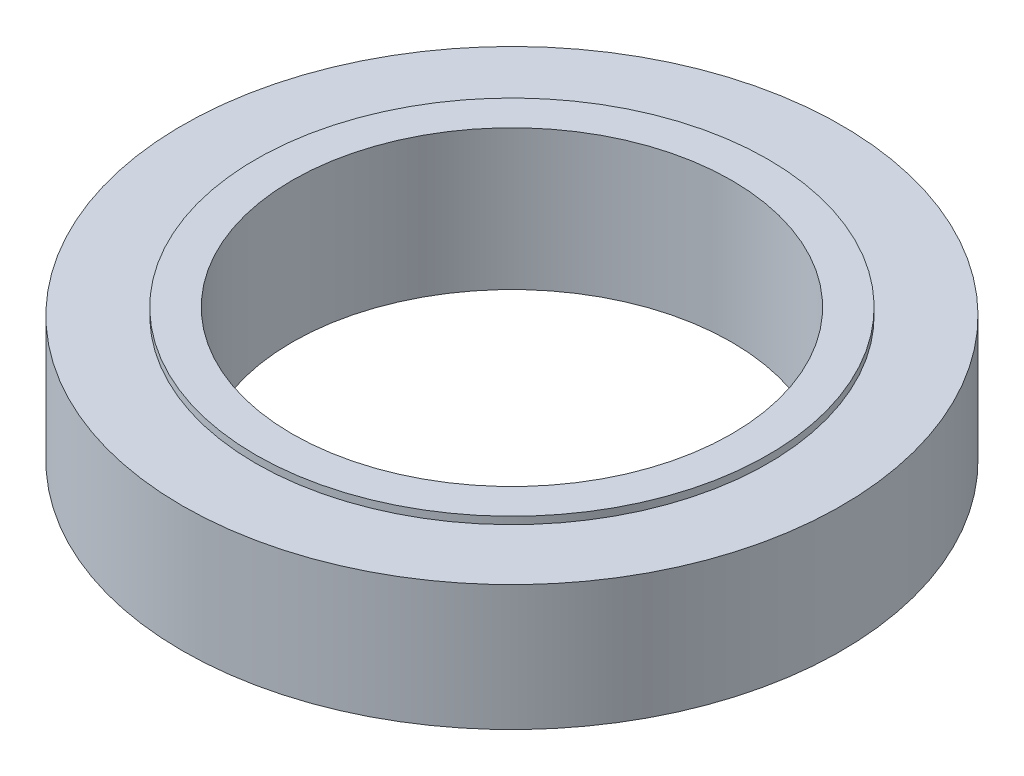
from build123d import *

# Parameters (mm, degrees)
SKETCH2_R           = 16.66875
SKETCH2_R_2         = 11.1125
BOSS_EXTRUDE1_DEPTH = 3.175
SKETCH2_3_R         = 12.954
SKETCH2_3_R_2       = 11.1125
BOSS_EXTRUDE2_DEPTH = 3.5433


with BuildPart() as part:
    # Sketch2 → Boss-Extrude1 (new, symmetric)
    with BuildSketch(Plane(origin=(0, 0, 0), x_dir=(1, 0, 0), z_dir=(0, 1, 0))):
        Circle(SKETCH2_R)
        Circle(SKETCH2_R_2, mode=Mode.SUBTRACT)
    extrude(amount=BOSS_EXTRUDE1_DEPTH, both=True)

    # Sketch2_3 → Boss-Extrude2 (add, symmetric)
    with BuildSketch(Plane(origin=(0, 0, 0), x_dir=(1, 0, 0), z_dir=(0, 1, 0))):
        Circle(SKETCH2_3_R)
        Circle(SKETCH2_3_R_2, mode=Mode.SUBTRACT)
    extrude(amount=BOSS_EXTRUDE2_DEPTH, both=True)


solid = part.part
